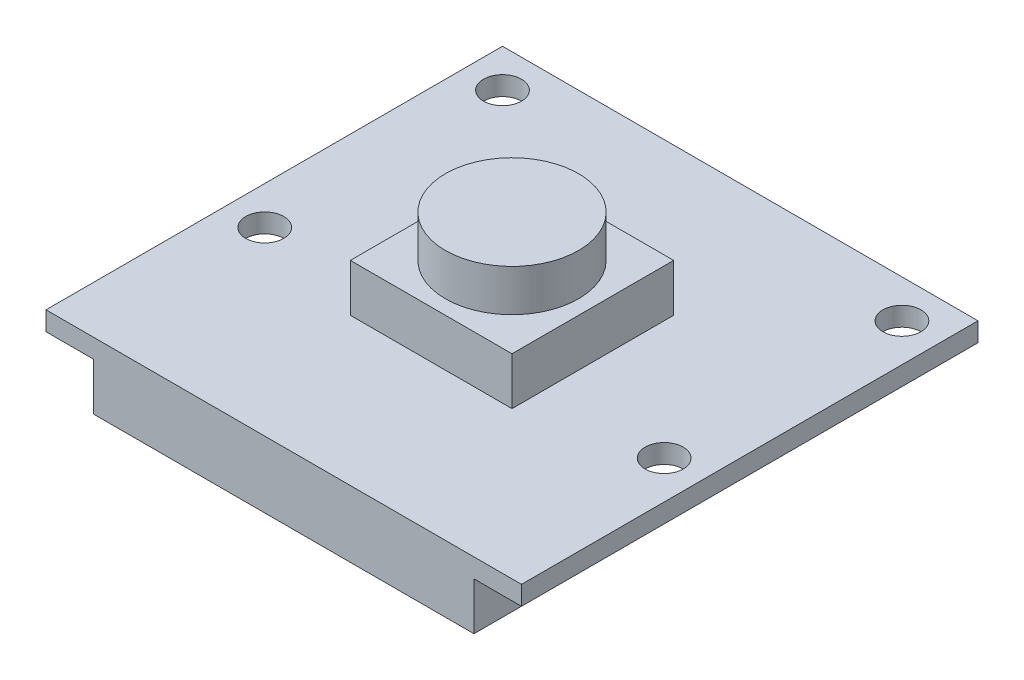
from build123d import *

# Parameters (mm, degrees)
SKETCH1_W           = 25
SKETCH1_H           = 24
SKETCH1_R           = 1
BOSS_EXTRUDE1_DEPTH = 1
SKETCH2_W           = 8.5
SKETCH2_H           = 8.5
BOSS_EXTRUDE2_DEPTH = 2.5
SKETCH3_R           = 3.5
BOSS_EXTRUDE3_DEPTH = 2.2
SKETCH4_W           = 20
SKETCH4_H           = 6
BOSS_EXTRUDE4_DEPTH = 2.5


with BuildPart() as part:
    # Sketch1 → Boss-Extrude1 (new body)
    with BuildSketch(Plane(origin=(0, 0, 0), x_dir=(1, 0, 0), z_dir=(0, 1, 0))):
        with Locations((12.5, 12)):
            Rectangle(SKETCH1_W, SKETCH1_H)
        with Locations((2, 22)):
            Circle(SKETCH1_R, mode=Mode.SUBTRACT)
        with Locations((2, 9.5)):
            Circle(SKETCH1_R, mode=Mode.SUBTRACT)
        with Locations((23, 9.5)):
            Circle(SKETCH1_R, mode=Mode.SUBTRACT)
        with Locations((23, 22)):
            Circle(SKETCH1_R, mode=Mode.SUBTRACT)
    extrude(amount=BOSS_EXTRUDE1_DEPTH)

    # Sketch2 → Boss-Extrude2 (add)
    with BuildSketch(Plane(origin=(0, 1, 0), x_dir=(1, 0, 0), z_dir=(0, 1, 0))):
        with Locations((12.5, 12)):
            Rectangle(SKETCH2_W, SKETCH2_H)
    extrude(amount=BOSS_EXTRUDE2_DEPTH)

    # Sketch3 → Boss-Extrude3 (add)
    with BuildSketch(Plane(origin=(0, 3.5, 0), x_dir=(1, 0, 0), z_dir=(0, 1, 0))):
        with Locations((12.5, 12)):
            Circle(SKETCH3_R)
    extrude(amount=BOSS_EXTRUDE3_DEPTH)

    # Sketch4 → Boss-Extrude4 (add)
    with BuildSketch(Plane.XZ):
        with Locations((12.5, -3)):
            Rectangle(SKETCH4_W, SKETCH4_H)
    extrude(amount=BOSS_EXTRUDE4_DEPTH)


solid = part.part
